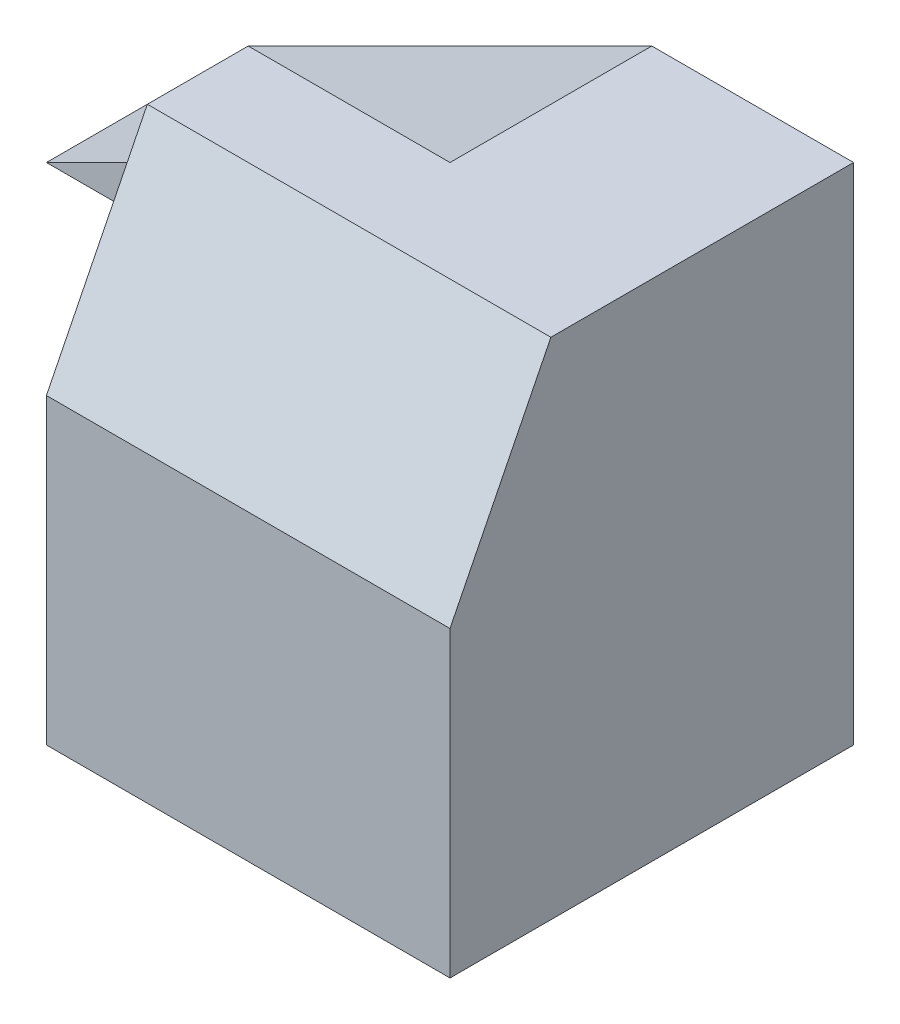
from build123d import *

# Parameters (mm, degrees)
SKETCH1_W           = 20
SKETCH1_H           = 25
BOSS_EXTRUDE1_DEPTH = 20
CUT_EXTRUDE1_DEPTH  = 20
SKETCH4_W           = 10
SKETCH4_H           = 10
BOSS_EXTRUDE2_DEPTH = 10
CUT_EXTRUDE2_DEPTH  = 50
CUT_EXTRUDE3_DEPTH  = 15


with BuildPart() as part:
    # Sketch1 → Boss-Extrude1 (new body)
    with BuildSketch(Plane.XY):
        with Locations((10, 12.5)):
            Rectangle(SKETCH1_W, SKETCH1_H)
    extrude(amount=BOSS_EXTRUDE1_DEPTH)

    # Sketch3 → Cut-Extrude1 (cut)
    with BuildSketch(Plane.ZY):
        Polygon((15, 25), (20, 15), (20, 25), align=None)
    extrude(amount=-CUT_EXTRUDE1_DEPTH, mode=Mode.SUBTRACT)

    # Sketch4 → Boss-Extrude2 (add)
    with BuildSketch(Plane.ZY):
        with Locations((5, 20)):
            Rectangle(SKETCH4_W, SKETCH4_H)
    extrude(amount=BOSS_EXTRUDE2_DEPTH)

    # Sketch5 → Cut-Extrude2 (cut)
    with BuildSketch(Plane.XY.offset(10)):
        Polygon((-10, 15), (10, 25), (-10, 25), align=None)
    extrude(amount=-CUT_EXTRUDE2_DEPTH, mode=Mode.SUBTRACT)

    # Sketch6 → Cut-Extrude3 (cut)
    with BuildSketch(Plane.XZ):
        Polygon((0, 10), (5, 0), (0, 0), align=None)
    extrude(amount=-CUT_EXTRUDE3_DEPTH, mode=Mode.SUBTRACT)


solid = part.part
